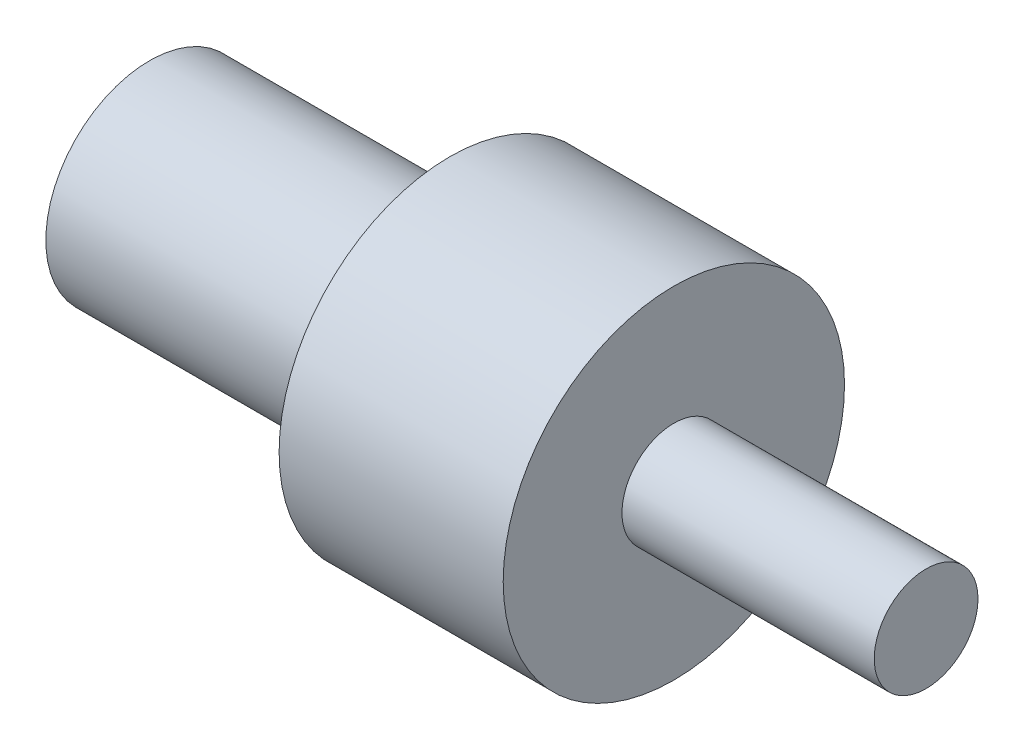
from build123d import *


with BuildPart() as part:
    # Skica1 → Rotovat1 (revolve)
    with BuildSketch(Plane.XY, mode=Mode.PRIVATE) as rotovat1_sk:
        Polygon((0, 0), (0, 17.545735619), (50.749167087, 17.545735619), (50.749167087, 28.852573965), (88.636993826, 28.852573965), (88.636993826, 8.772867809), (131.285594605, 8.772867809), (131.285594605, 0), align=None)
    revolve(rotovat1_sk.sketch.rotate(Axis((131.285594605, 0, 0), (-1, 0, 0)), 90), axis=Axis((131.285594605, 0, 0), (-1, 0, 0)))  # turned: the seam where the file's is


solid = part.part
